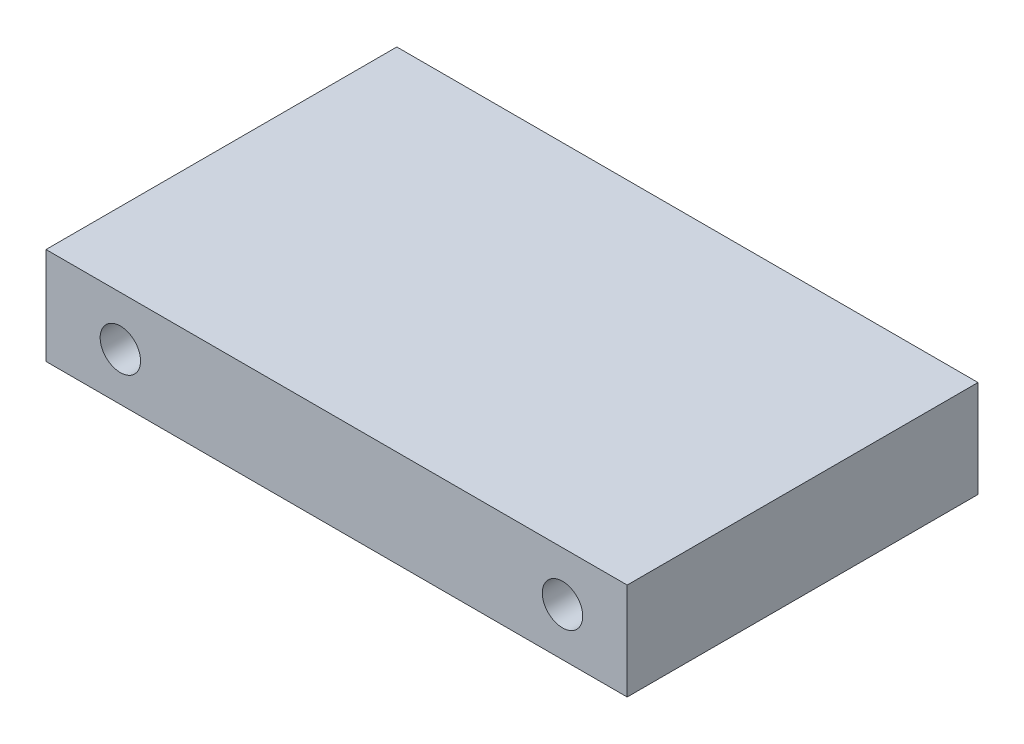
from build123d import *

# Parameters (mm, degrees)
SIDE_W                               = 35.95
SIDE_H                               = 6
AUFSATZ_LINEAR_AUSTRAGEN1_DEPTH      = 10.85
AUFSATZ_LINEAR_AUSTRAGEN1_DEPTH_BACK = 10.85
SKIZZE5_R                            = 1.25
SCHNITT_LINEAR_AUSTRAGEN1_DEPTH      = 11.85
SCHNITT_LINEAR_AUSTRAGEN1_DEPTH_BACK = 11.85


with BuildPart() as part:
    # Side → Aufsatz-Linear austragen1 (new body, two sides)
    with BuildSketch(Plane.XY) as aufsatz_linear_austragen1_sk:
        with Locations((5.375, 567)):
            Rectangle(SIDE_W, SIDE_H)
    extrude(amount=AUFSATZ_LINEAR_AUSTRAGEN1_DEPTH)
    extrude(aufsatz_linear_austragen1_sk.sketch, amount=-AUFSATZ_LINEAR_AUSTRAGEN1_DEPTH_BACK)

    # Skizze5 → Schnitt-Linear austragen1 (cut, two sides)
    with BuildSketch(Plane.XY) as schnitt_linear_austragen1_sk:
        with Locations((-8, 566.953897676)):
            Circle(SKIZZE5_R)
        with Locations((19.35, 566.953897676)):
            Circle(SKIZZE5_R)
    extrude(amount=SCHNITT_LINEAR_AUSTRAGEN1_DEPTH, mode=Mode.SUBTRACT)
    extrude(schnitt_linear_austragen1_sk.sketch, amount=-SCHNITT_LINEAR_AUSTRAGEN1_DEPTH_BACK, mode=Mode.SUBTRACT)


solid = part.part
